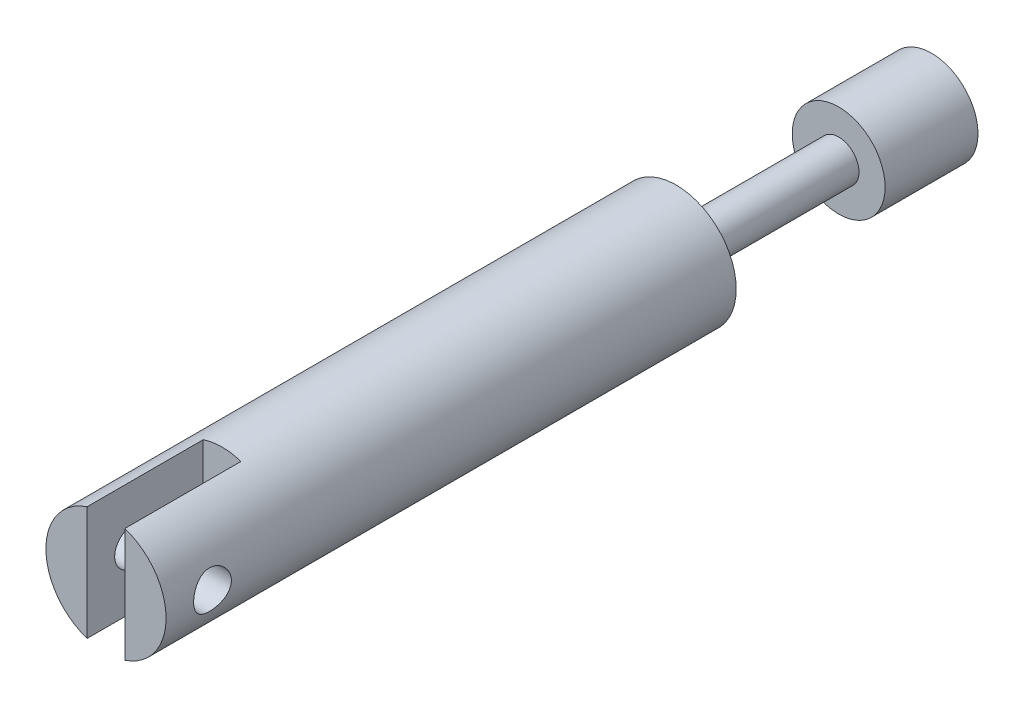
from build123d import *

# Parameters (mm, degrees)
SKETCH1_W          = 14
SKETCH1_H          = 1.75
SKETCH4_W          = 3.25
SKETCH4_H          = 11
CUT_EXTRUDE1_DEPTH = 10
SKETCH5_R          = 1.625
CUT_EXTRUDE2_DEPTH = 12


with BuildPart() as part:
    # Sketch1 → Revolve1 (revolve)
    with BuildSketch(Plane(origin=(0, 0, 0), x_dir=(0, 0, -1), z_dir=(1, 0, 0))):
        Polygon((0, 5.175), (0, 0), (49.1, 0), (49.1, 1.75), (49.1, 5.175), align=None)
        with Locations((56.1, 0.875)):
            Rectangle(SKETCH1_W, SKETCH1_H)
        Polygon((63.1, 1.75), (63.1, 0), (71.1, 0), (71.1, 4), (63.1, 4), align=None)
    revolve(axis=Axis((0, 0, -49.1), (0, 0, -1)))

    # Sketch4 → Cut-Extrude1 (cut)
    with BuildSketch(Plane.XY):
        Rectangle(SKETCH4_W, SKETCH4_H)
    extrude(amount=-CUT_EXTRUDE1_DEPTH, mode=Mode.SUBTRACT)

    # Sketch5 → Cut-Extrude2 (cut)
    with BuildSketch(Plane(origin=(5.175, 0, 0), x_dir=(0, 0, -1), z_dir=(1, 0, 0))):
        with Locations((4, 0)):
            Circle(SKETCH5_R)
    extrude(amount=-CUT_EXTRUDE2_DEPTH, mode=Mode.SUBTRACT)


solid = part.part
